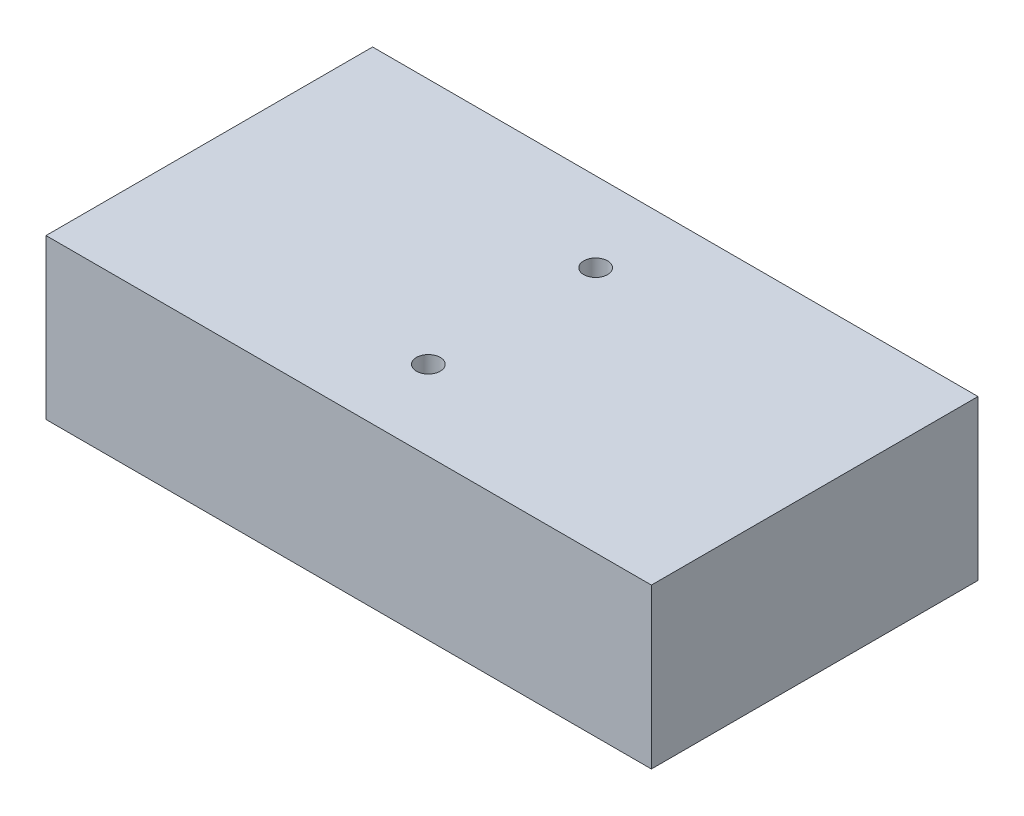
from build123d import *

# Parameters (mm, degrees)
SKETCH1_W           = 76
SKETCH1_H           = 41
SKETCH1_R           = 1.5
BOSS_EXTRUDE1_DEPTH = 20


with BuildPart() as part:
    # Sketch1 → Boss-Extrude1 (new body)
    with BuildSketch(Plane(origin=(0, 0, 0), x_dir=(1, 0, 0), z_dir=(0, 1, 0))):
        with Locations((5.45691906, -9.238903394)):
            Rectangle(SKETCH1_W, SKETCH1_H)
        with Locations((5.45691906, 1.261096606)):
            Circle(SKETCH1_R, mode=Mode.SUBTRACT)
        with Locations((5.45691906, -19.738903394)):
            Circle(SKETCH1_R, mode=Mode.SUBTRACT)
    extrude(amount=BOSS_EXTRUDE1_DEPTH)


solid = part.part
